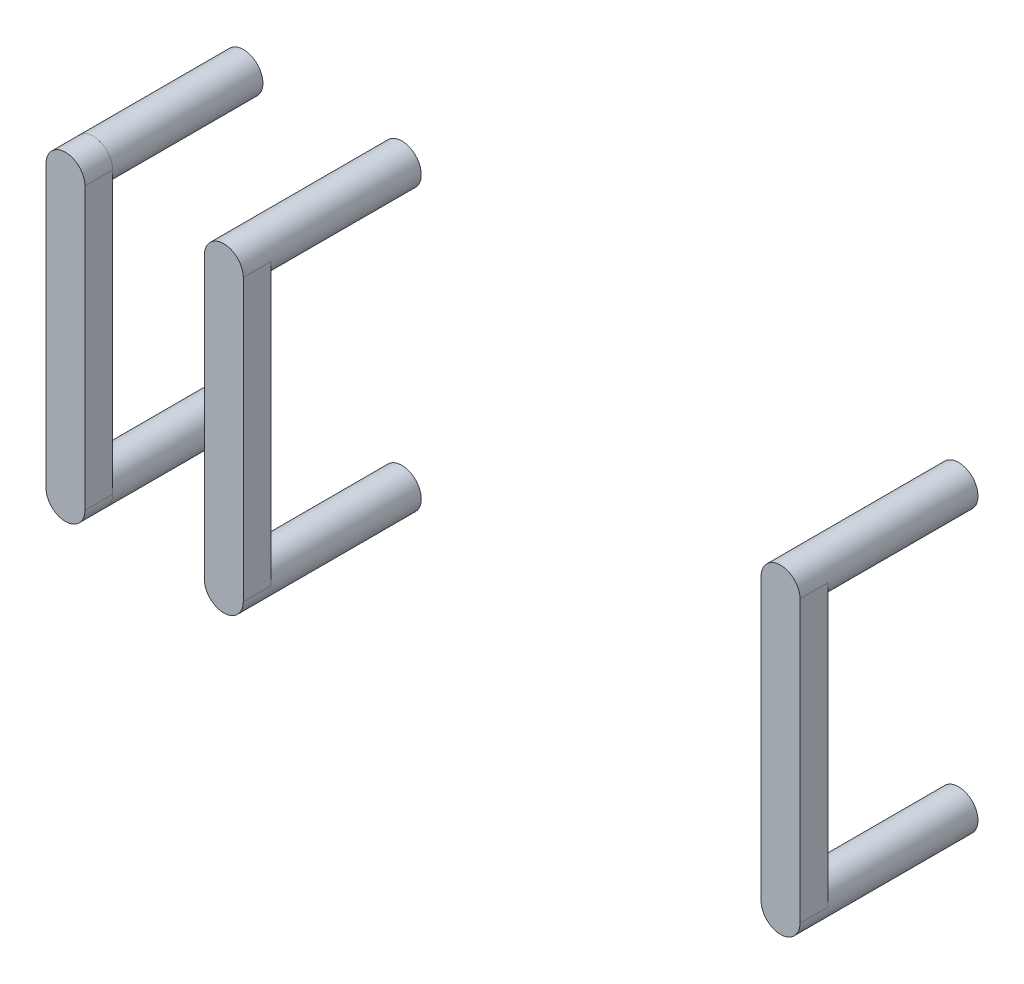
from build123d import *

# Parameters (mm, degrees)
SKIZZE1_R                         = 3.5
AUFSATZ_LINEAR_AUSTRAGEN1_DEPTH   = 27
AUFSATZ_LINEAR_AUSTRAGEN1_2_DEPTH = 27
AUFSATZ_LINEAR_AUSTRAGEN1_3_DEPTH = 27
AUFSATZ_LINEAR_AUSTRAGEN1_4_DEPTH = 27
AUFSATZ_LINEAR_AUSTRAGEN1_5_DEPTH = 27
AUFSATZ_LINEAR_AUSTRAGEN1_6_DEPTH = 27
SKIZZE2_R                         = 2.1
SCHNITT_LINEAR_AUSTRAGEN1_DEPTH   = 5.7
AUFSATZ_LINEAR_AUSTRAGEN2_DEPTH   = 5


with BuildPart() as part:
    # Skizze1 → Aufsatz-Linear austragen1 (new body)
    with BuildSketch(Plane.XY):
        with Locations((-50.05, -80.201897344)):
            Circle(SKIZZE1_R)
    extrude(amount=AUFSATZ_LINEAR_AUSTRAGEN1_DEPTH)


with BuildPart() as body_2:
    # Skizze1 → Aufsatz-Linear austragen1 2 (new body)
    with BuildSketch(Plane.XY):
        with Locations(Location((50.05, -80.201897344, 0), (0, 0, 180))):
            Circle(SKIZZE1_R)
    extrude(amount=AUFSATZ_LINEAR_AUSTRAGEN1_2_DEPTH)


with BuildPart() as body_3:
    # Skizze1 → Aufsatz-Linear austragen1 3 (new body)
    with BuildSketch(Plane.XY):
        with Locations((50.05, -29.698102656)):
            Circle(SKIZZE1_R)
    extrude(amount=AUFSATZ_LINEAR_AUSTRAGEN1_3_DEPTH)


with BuildPart() as body_4:
    # Skizze1 → Aufsatz-Linear austragen1 4 (new body)
    with BuildSketch(Plane.XY):
        with Locations(Location((-50.05, -29.698102656, 0), (0, 0, 180))):
            Circle(SKIZZE1_R)
    extrude(amount=AUFSATZ_LINEAR_AUSTRAGEN1_4_DEPTH)


with BuildPart() as body_5:
    # Skizze1 → Aufsatz-Linear austragen1 5 (new body)
    with BuildSketch(Plane.XY):
        with Locations(Location((-78.525, -80.201897344, 0), (0, 0, 180))):
            Circle(SKIZZE1_R)
    extrude(amount=AUFSATZ_LINEAR_AUSTRAGEN1_5_DEPTH)


with BuildPart() as body_6:
    # Skizze1 → Aufsatz-Linear austragen1 6 (new body)
    with BuildSketch(Plane.XY):
        with Locations((-78.525, -29.698102656)):
            Circle(SKIZZE1_R)
    extrude(amount=AUFSATZ_LINEAR_AUSTRAGEN1_6_DEPTH)


with BuildPart() as schnitt_linear_austragen1_tool:
    # Skizze2 → Schnitt-Linear austragen1 (new body)
    with BuildSketch(Plane(origin=(0, 0, 0), x_dir=(-1, 0, 0), z_dir=(0, 0, -1))):
        with Locations((50.05, -80.201897344)):
            Circle(SKIZZE2_R)
        with Locations(Location((50.05, -29.698102656, 0), (0, 0, 180))):
            Circle(SKIZZE2_R)
        with Locations((-50.05, -29.698102656)):
            Circle(SKIZZE2_R)
        with Locations(Location((-50.05, -80.201897344, 0), (0, 0, 180))):
            Circle(SKIZZE2_R)
    extrude(amount=-SCHNITT_LINEAR_AUSTRAGEN1_DEPTH)


with BuildPart() as part_1:
    add(part.part)

    # Schnitt-Linear austragen1: cut by schnitt_linear_austragen1_tool
    add(schnitt_linear_austragen1_tool.part, mode=Mode.SUBTRACT)



with BuildPart() as body_2_1:
    add(body_2.part)

    # Schnitt-Linear austragen1: cut by schnitt_linear_austragen1_tool
    add(schnitt_linear_austragen1_tool.part, mode=Mode.SUBTRACT)


with BuildPart() as body_3_1:
    add(body_3.part)

    # Schnitt-Linear austragen1: cut by schnitt_linear_austragen1_tool
    add(schnitt_linear_austragen1_tool.part, mode=Mode.SUBTRACT)


with BuildPart() as body_4_1:
    add(body_4.part)

    # Schnitt-Linear austragen1: cut by schnitt_linear_austragen1_tool
    add(schnitt_linear_austragen1_tool.part, mode=Mode.SUBTRACT)


with BuildPart() as part_2:
    add(part_1.part)

    add(body_4_1.part)  # Aufsatz-Linear austragen2 merges body 4

    add(body_2_1.part)  # Aufsatz-Linear austragen2 merges body 2

    add(body_3_1.part)  # Aufsatz-Linear austragen2 merges body 3
    # Skizze4 → Aufsatz-Linear austragen2 (add)
    with BuildSketch(Plane.XY.offset(27)):
        with BuildLine():
            Line((-53.55, -80.201897344), (-53.55, -29.698102656))
            ThreePointArc((-53.55, -29.698102656), (-50.05, -26.198102656), (-46.55, -29.698102656))
            Line((-46.55, -29.698102656), (-46.55, -80.201897344))
            ThreePointArc((-46.55, -80.201897344), (-50.05, -83.701897344), (-53.55, -80.201897344))
        make_face()
        with BuildLine():
            Line((46.55, -29.698102656), (46.55, -80.201897344))
            ThreePointArc((46.55, -80.201897344), (50.05, -83.701897344), (53.55, -80.201897344))
            Line((53.55, -80.201897344), (53.55, -29.698102656))
            ThreePointArc((53.55, -29.698102656), (50.05, -26.198102656), (46.55, -29.698102656))
        make_face()
        with BuildLine():
            Line((-82.025, -29.698102656), (-82.025, -80.201897344))
            ThreePointArc((-82.025, -80.201897344), (-78.525, -83.701897344), (-75.025, -80.201897344))
            Line((-75.025, -80.201897344), (-75.025, -29.698102656))
            ThreePointArc((-75.025, -29.698102656), (-78.525, -26.198102656), (-82.025, -29.698102656))
        make_face()
    extrude(amount=AUFSATZ_LINEAR_AUSTRAGEN2_DEPTH)


solid = Compound([body_5.part, body_6.part, part_2.part])
